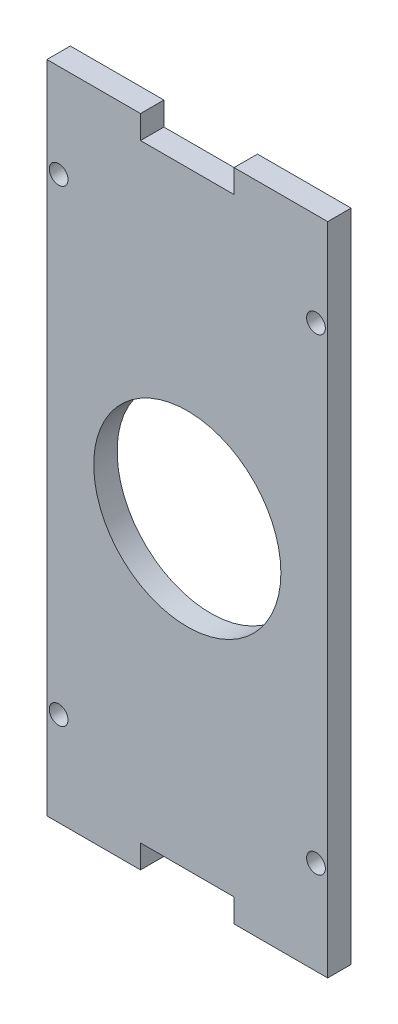
from build123d import *

# Parameters (mm, degrees)
BOSS_EXTRUDE1_DEPTH = 5
SKETCH3_R           = 2
CUT_EXTRUDE1_DEPTH  = 10
SKETCH4_R           = 20
CUT_EXTRUDE2_DEPTH  = 300


with BuildPart() as part:
    # Sketch2 → Boss-Extrude1 (new body)
    with BuildSketch(Plane.XY):
        Polygon((-5, 70), (-25, 70), (-25, -70), (-5, -70), (-5, -65), (15, -65), (15, -70), (35, -70), (35, 70), (15, 70), (15, 65), (-5, 65), align=None)
    extrude(amount=BOSS_EXTRUDE1_DEPTH)

    # Sketch3 → Cut-Extrude1 (cut)
    with BuildSketch(Plane.XY.offset(5)):
        with Locations((-22.5, 50)):
            Circle(SKETCH3_R)
        with Locations((-22.5, -50)):
            Circle(SKETCH3_R)
    cut_extrude1 = extrude(amount=-CUT_EXTRUDE1_DEPTH, mode=Mode.SUBTRACT)

    # Mirror1: Cut-Extrude1 across plane
    add(cut_extrude1.mirror(Plane.ZY.offset(-5)), mode=Mode.SUBTRACT)

    # Sketch4 → Cut-Extrude2 (cut)
    with BuildSketch(Plane.XY.offset(5)):
        with Locations((5, 0)):
            Circle(SKETCH4_R)
    extrude(amount=-CUT_EXTRUDE2_DEPTH, mode=Mode.SUBTRACT)


solid = part.part
